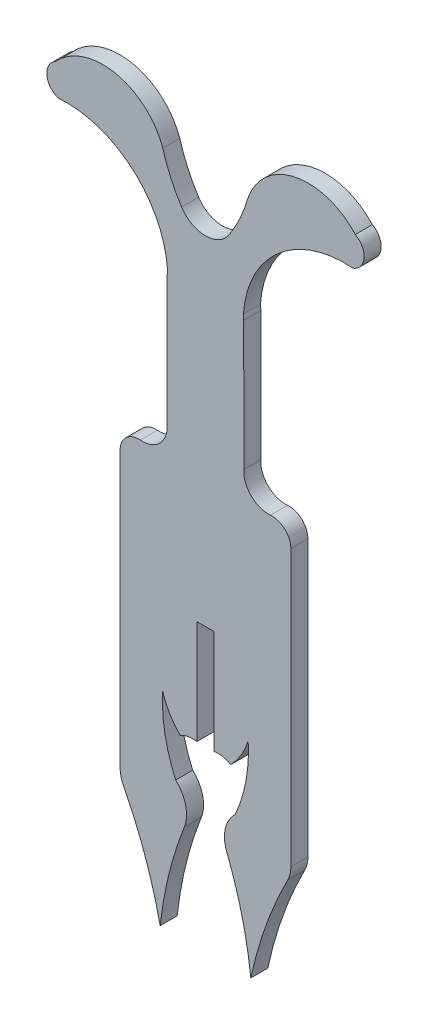
from build123d import *

# Parameters (mm, degrees)
BOSS_EXTRUDE1_DEPTH = 1.524


with BuildPart() as part:
    # Sketch1 → Boss-Extrude1 (new body)
    with BuildSketch(Plane.XY):
        with BuildLine():
            Line((0.758413423, -14.514612412), (0.756426596, -5.229573284))
            Line((0.756426596, -5.229573284), (-0.767567777, -5.228579871))
            Line((-0.767567777, -5.228579871), (-0.767567777, -14.513618998))
            ThreePointArc((-0.767567777, -14.513618998), (-1.539192536, -14.521879258), (-2.263766939, -14.78733158))
            ThreePointArc((-2.263766939, -14.78733158), (-3.206305559, -13.566940945), (-3.825331329, -12.1546593))
            ThreePointArc((-3.825331329, -12.1546593), (-3.623089301, -15.369727095), (-2.663937168, -18.445046583))
            ThreePointArc((-2.663937168, -18.445046583), (-1.772934243, -19.968018634), (-1.903339021, -21.727656288))
            ThreePointArc((-1.903339021, -21.727656288), (-3.266929983, -25.997412135), (-4.052166969, -30.410302139))
            ThreePointArc((-4.052166969, -30.410302139), (-5.395158951, -25.68457677), (-7.349213338, -21.177052042))
            ThreePointArc((-7.349213338, -21.177052042), (-7.559215071, -20.612929546), (-7.63057286, -20.015231476))
            Line((-7.63057286, -20.015231476), (-7.631892886, 4.626897175))
            ThreePointArc((-7.631892886, 4.626897175), (-7.092287621, 5.859442088), (-5.820556253, 6.298805414))
            ThreePointArc((-5.820556253, 6.298805414), (-4.085125664, 6.930306858), (-3.428174811, 8.656264268))
            Line((-3.428174811, 8.656264268), (-3.431470931, 20.183759219))
            ThreePointArc((-3.431470931, 20.183759219), (-3.418767766, 20.417805376), (-3.390090239, 20.650435067))
            ThreePointArc((-3.390090239, 20.650435067), (-6.519567928, 26.925166891), (-13.182414969, 29.109739933))
            ThreePointArc((-13.182414969, 29.109739933), (-14.180468361, 30.396049042), (-13.396765315, 31.823112892))
            ThreePointArc((-13.396765315, 31.823112892), (-8.064833076, 33.586641612), (-3.820754211, 29.9086898))
            ThreePointArc((-3.820754211, 29.9086898), (-3.115822585, 27.98554328), (-2.136235135, 26.186702108))
            ThreePointArc((-2.136235135, 26.186702108), (-0.000993472, 25.022326708), (2.134248191, 26.186702108))
            ThreePointArc((2.134248191, 26.186702108), (3.113835641, 27.98554328), (3.818767267, 29.9086898))
            ThreePointArc((3.818767267, 29.9086898), (8.062846132, 33.586641612), (13.394778371, 31.823112892))
            ThreePointArc((13.394778371, 31.823112892), (14.178481417, 30.396049042), (13.180428025, 29.109739933))
            ThreePointArc((13.180428025, 29.109739933), (6.517580984, 26.925166891), (3.388103295, 20.650435067))
            ThreePointArc((3.388103295, 20.650435067), (3.412047002, 20.417632477), (3.420040198, 20.183738364))
            Line((3.420040198, 20.183738364), (3.421535659, 8.656441281))
            ThreePointArc((3.421535659, 8.656441281), (4.079205123, 6.93199833), (5.813550357, 6.300904656))
            ThreePointArc((5.813550357, 6.300904656), (7.087362904, 5.86275757), (7.628225836, 4.6290483))
            Line((7.628225836, 4.6290483), (7.631801236, -20.008478102))
            ThreePointArc((7.631801236, -20.008478102), (7.56045, -20.606653876), (7.350236218, -21.171202742))
            ThreePointArc((7.350236218, -21.171202742), (5.394278235, -25.681479256), (4.050180025, -30.410302139))
            ThreePointArc((4.050180025, -30.410302139), (3.265080471, -25.998057724), (1.901795058, -21.728896802))
            ThreePointArc((1.901795058, -21.728896802), (1.770271466, -19.970622492), (2.657373106, -18.446851614))
            ThreePointArc((2.657373106, -18.446851614), (3.616525238, -15.371532126), (3.818767267, -12.156464331))
            ThreePointArc((3.818767267, -12.156464331), (3.199964786, -13.568369499), (2.257818447, -14.788514159))
            ThreePointArc((2.257818447, -14.788514159), (1.531710448, -14.522401162), (0.758413423, -14.514612412))
        make_face()
    extrude(amount=BOSS_EXTRUDE1_DEPTH)


solid = part.part
